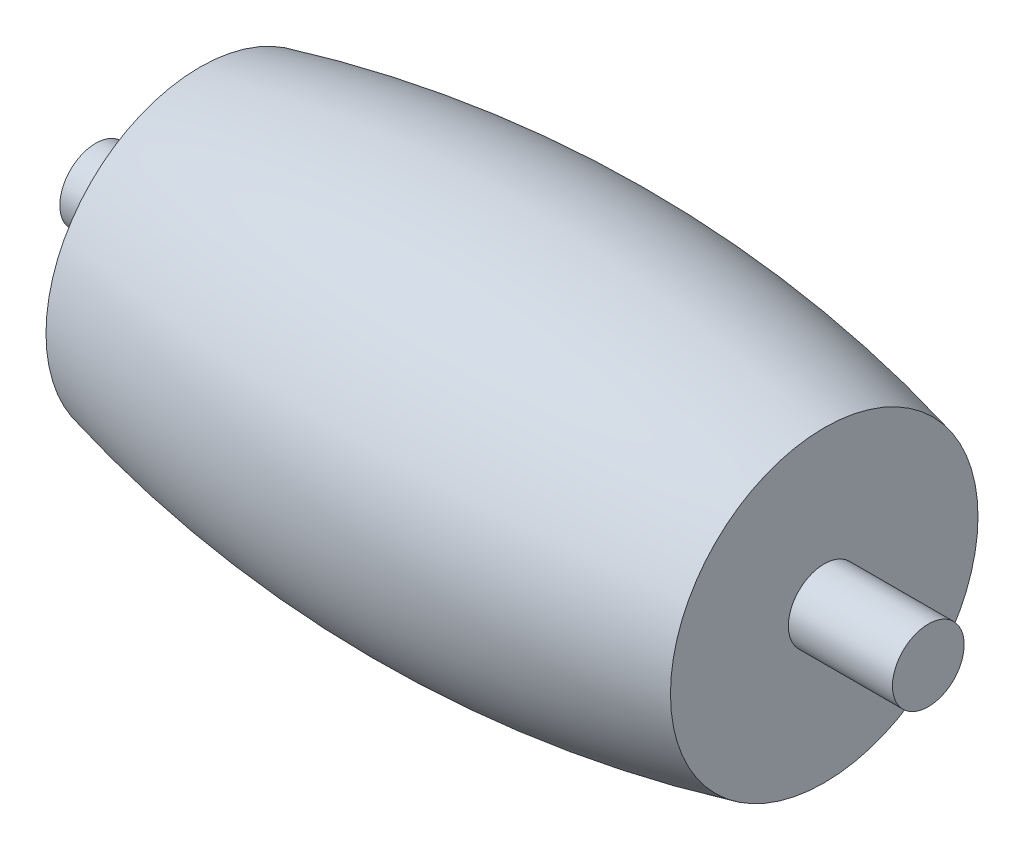
from build123d import *

# Parameters (mm, degrees)
SKETCH3_R           = 0.775
BOSS_EXTRUDE1_DEPTH = 2.25


with BuildPart() as part:
    # Sweep1: sweep along a path in Sketch1
    with BuildLine(Plane(origin=(0, 0, 0), x_dir=(0, 0, -1), z_dir=(1, 0, 0))) as sweep1_path:
        CenterArc((0, 0), 4.15, 0, 360)
    # Sketch2 → Sweep1 (sweep)
    with BuildSketch(Plane.XY):
        with BuildLine():
            Line((6.75, 0), (-6.75, 0))
            Line((-6.75, 0), (-6.75, 3.32420652))
            ThreePointArc((-6.75, 3.32420652), (0, 4.15), (6.75, 3.32420652))
            Line((6.75, 3.32420652), (6.75, 0))
        make_face()
    sweep(path=sweep1_path.line)

    # Sketch3 → Boss-Extrude1 (add)
    with BuildSketch(Plane.ZY.offset(6.75)):
        Circle(SKETCH3_R)
    boss_extrude1 = extrude(amount=BOSS_EXTRUDE1_DEPTH)

    # Mirror1: Boss-Extrude1 across plane
    add(boss_extrude1.mirror(Plane(origin=(0, 0, 0), x_dir=(0, 0, 1), z_dir=(1, 0, 0))))


solid = part.part
